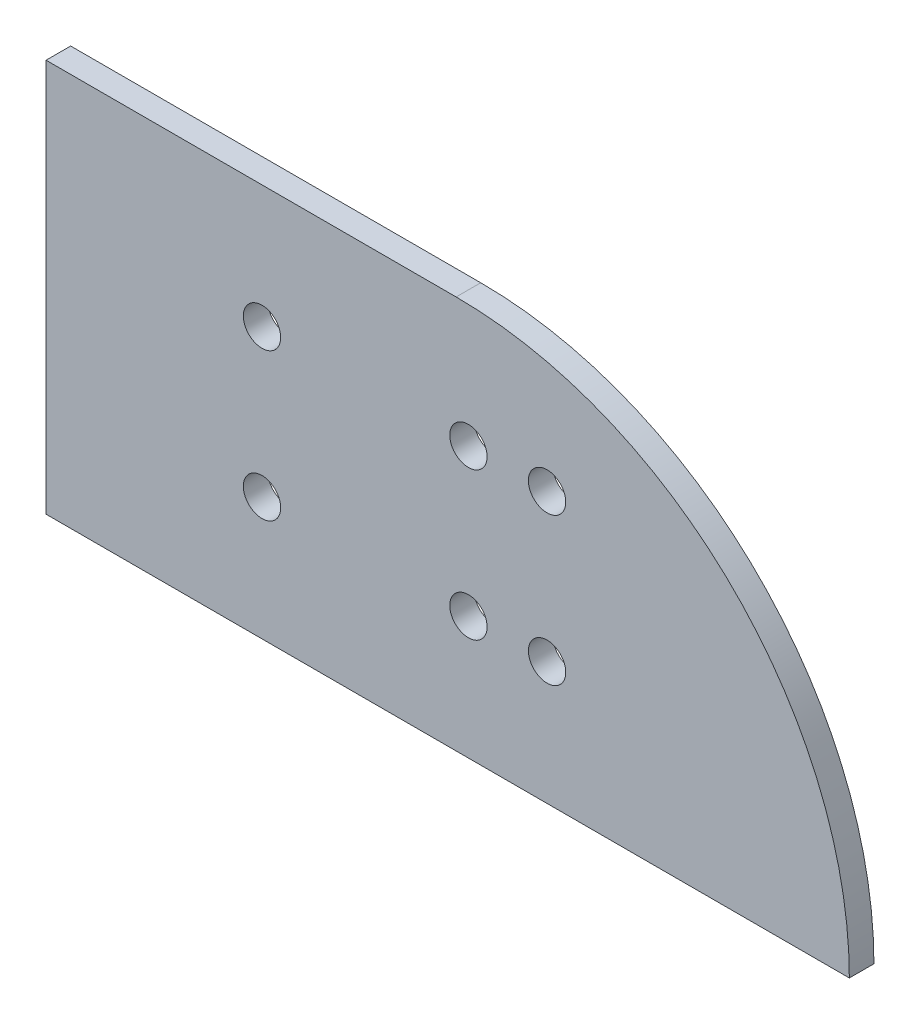
from build123d import *

# Parameters (mm, degrees)
BOSS_EXTRUDE1_DEPTH     = 3.175
SKETCH3_R               = 2.413
CUT_EXTRUDE1_DEPTH      = 1
CUT_EXTRUDE1_DEPTH_BACK = 4.175


with BuildPart() as part:
    # Sketch1 → Boss-Extrude1 (new body)
    with BuildSketch(Plane.XY):
        with BuildLine():
            Line((0, 50.8), (0, 0))
            Line((0, 0), (103.778975516, 0))
            ThreePointArc((103.778975516, 0), (88.9, 35.921024484), (52.978975516, 50.8))
            Line((52.978975516, 50.8), (0, 50.8))
        make_face()
    extrude(amount=BOSS_EXTRUDE1_DEPTH)

    # Sketch3 → Cut-Extrude1 (cut, two sides)
    with BuildSketch(Plane.XY.offset(3.175)) as cut_extrude1_sk:
        with Locations((64.726475516, 15.875)):
            Circle(SKETCH3_R)
        with Locations((64.726475516, 34.925)):
            Circle(SKETCH3_R)
        with Locations((27.896475516, 15.875)):
            Circle(SKETCH3_R)
        with Locations((27.896475516, 34.925)):
            Circle(SKETCH3_R)
        with Locations((54.566475516, 34.925)):
            Circle(SKETCH3_R)
        with Locations((54.566475516, 15.875)):
            Circle(SKETCH3_R)
    extrude(amount=CUT_EXTRUDE1_DEPTH, mode=Mode.SUBTRACT)
    extrude(cut_extrude1_sk.sketch, amount=-CUT_EXTRUDE1_DEPTH_BACK, mode=Mode.SUBTRACT)


solid = part.part
